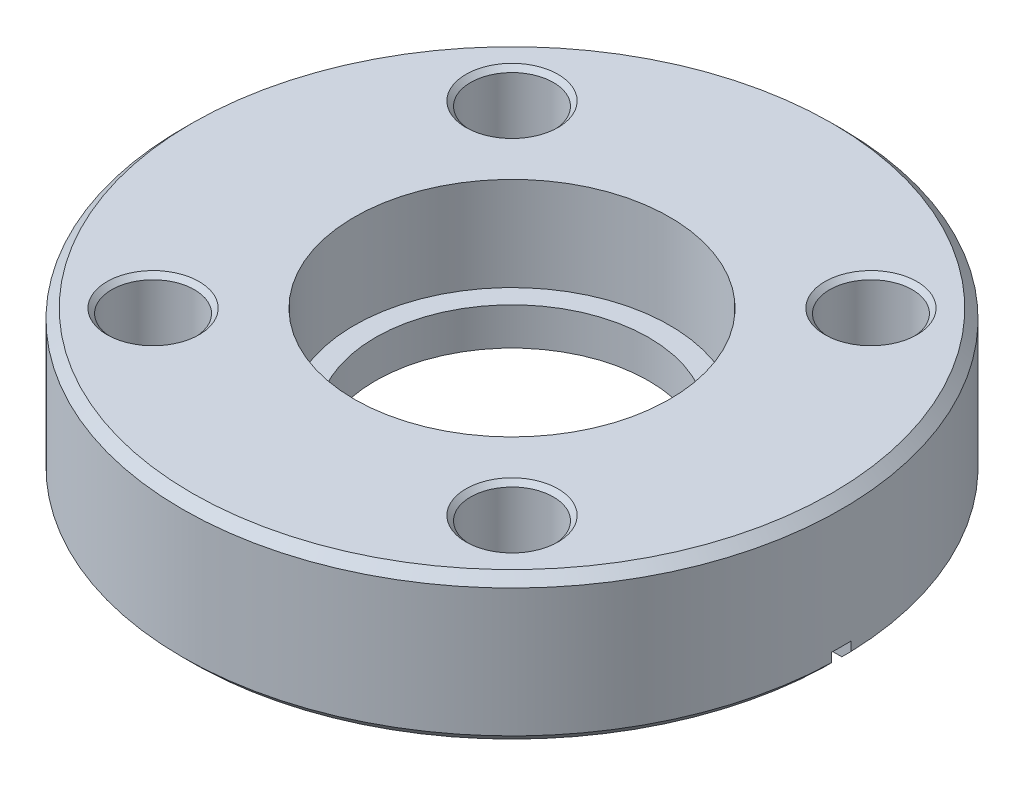
from build123d import *

# Parameters (mm, degrees)
SKETCH1_R                    = 26.797
SKETCH1_R_2                  = 11.1125
BOSS_EXTRUDE1_DEPTH          = 11.938
SKETCH2_R                    = 12.827
CUT_EXTRUDE1_DEPTH           = 7.62
CHAMFER1_SIZE                = 0.762
SKETCH4_R                    = 3.3655
CUT_EXTRUDE2_DEPTH           = 12.938
CHAMFER2_SIZE                = 0.381
CIRPATTERN1_COUNT            = 4
CHAMFER2_OF_CIRPATTERN1_SIZE = 0.381
CUT_EXTRUDE5_DEPTH           = 0.79375


with BuildPart() as part:
    # Sketch1 → Boss-Extrude1 (new body)
    with BuildSketch(Plane(origin=(0, 0, 0), x_dir=(1, 0, 0), z_dir=(0, 1, 0))):
        Circle(SKETCH1_R)
        Circle(SKETCH1_R_2, mode=Mode.SUBTRACT)
    extrude(amount=BOSS_EXTRUDE1_DEPTH)

    # Sketch2 → Cut-Extrude1 (cut)
    with BuildSketch(Plane(origin=(0, 11.938, 0), x_dir=(1, 0, 0), z_dir=(0, 1, 0))):
        Circle(SKETCH2_R)
    extrude(amount=-CUT_EXTRUDE1_DEPTH, mode=Mode.SUBTRACT)

    # Chamfer1
    chamfer1_edges = [part.edges().sort_by_distance(p)[0] for p in [
        (-26.797, 0, 0),
        (-26.797, 11.938, 0),
    ]]
    chamfer(chamfer1_edges, length=CHAMFER1_SIZE)

    # Sketch3 → Cut-Revolve1 (revolve, cut)
    with BuildSketch(Plane.XY):
        Polygon((-16.51, 0), (-16.51, 1.2446), (-13.843, 0.6604), (-13.843, 1.27), (0, 1.27), (0, 0), align=None)
    revolve(axis=Axis((0, 11.938, 0), (0, -1, 0)), mode=Mode.SUBTRACT)

    # Sketch4 → Cut-Extrude2 (cut, through all)
    with BuildSketch(Plane(origin=(0, 0, 0), x_dir=(1, 0, 0), z_dir=(0, 1, 0))):
        with Locations((14.592916197, 14.592916197)):
            Circle(SKETCH4_R)
    cut_extrude2 = extrude(amount=CUT_EXTRUDE2_DEPTH, mode=Mode.SUBTRACT)

    # Chamfer2
    chamfer2_edges = [part.edges().sort_by_distance(p)[0] for p in [
        (11.227416197, 0, -14.592916197),
        (11.227416197, 11.938, -14.592916197),
    ]]
    chamfer(chamfer2_edges, length=CHAMFER2_SIZE)

    # CirPattern1: Cut-Extrude2 ×4 about axis
    cirpattern1_axis = Axis((0, 0, 0), (0, 1, 0))
    for i in range(1, CIRPATTERN1_COUNT):
        add(cut_extrude2.rotate(cirpattern1_axis, i * 360 / CIRPATTERN1_COUNT), mode=Mode.SUBTRACT)

    # Chamfer2 of CirPattern1
    chamfer2_of_cirpattern1_edges = [part.edges().sort_by_distance(p)[0] for p in [
        (-14.592916197, 0, -11.227416197),
        (-14.592916197, 11.938, -11.227416197),
        (-11.227416197, 0, 14.592916197),
        (-11.227416197, 11.938, 14.592916197),
        (14.592916197, 0, 11.227416197),
        (14.592916197, 11.938, 11.227416197),
    ]]
    chamfer(chamfer2_of_cirpattern1_edges, length=CHAMFER2_OF_CIRPATTERN1_SIZE)

    # Sketch5 → Cut-Extrude5 (cut, symmetric)
    with BuildSketch(Plane.XY):
        Polygon((-15.875, 0.931973496), (-28.575, 1.597552293), (-28.575, 0), (-15.875, 0), align=None)
    cut_extrude5 = extrude(amount=CUT_EXTRUDE5_DEPTH, both=True, mode=Mode.SUBTRACT)

    # Mirror1: Cut-Extrude5 across plane
    add(cut_extrude5.mirror(Plane(origin=(0, 0, 0), x_dir=(0, 0, 1), z_dir=(1, 0, 0))), mode=Mode.SUBTRACT)


solid = part.part
